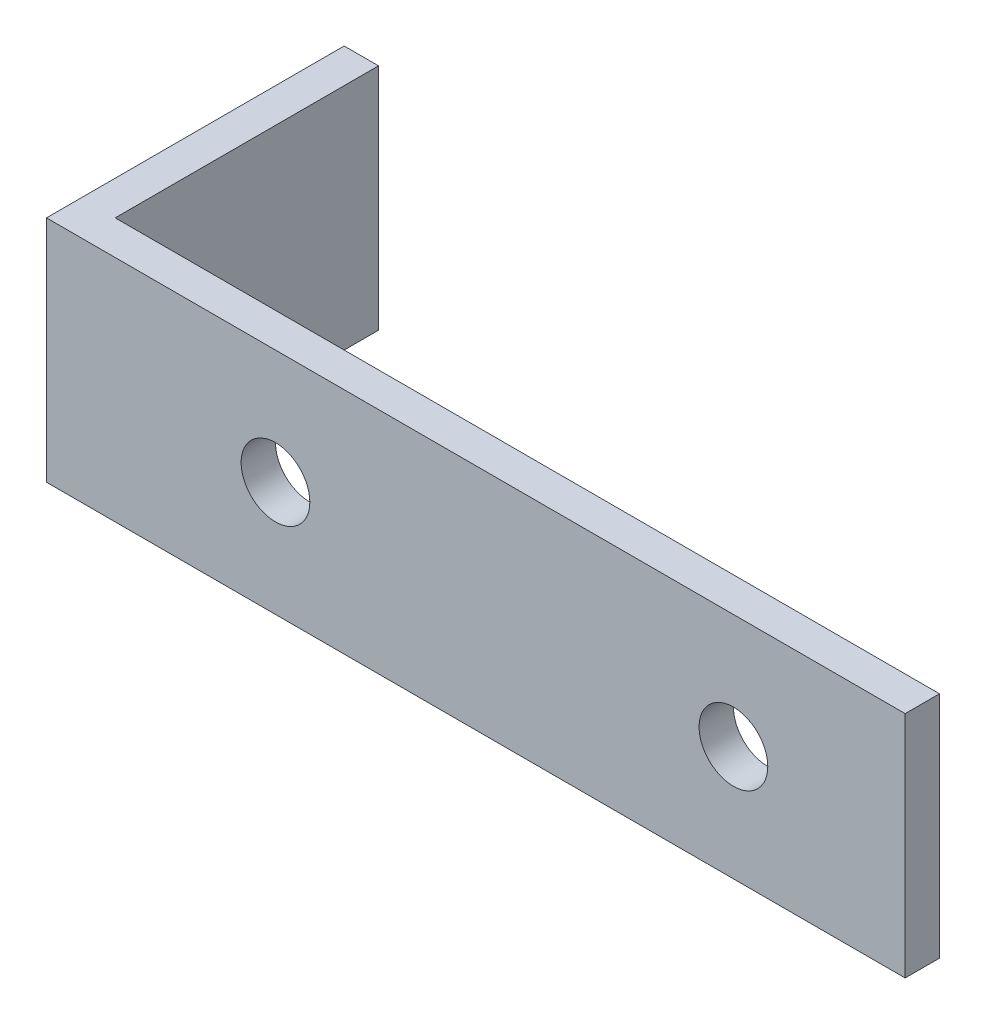
from build123d import *

# Parameters (mm, degrees)
SKETCH1_W           = 75
SKETCH1_H           = 20
SKETCH1_R           = 3
BOSS_EXTRUDE2_DEPTH = 3
SKETCH1_3_W         = 3
SKETCH1_3_H         = 20
BOSS_EXTRUDE3_DEPTH = 23


with BuildPart() as part:
    # Sketch1 → Boss-Extrude2 (new body)
    with BuildSketch(Plane.XY):
        with Locations((37.5, 10)):
            Rectangle(SKETCH1_W, SKETCH1_H)
        with Locations((60, 10)):
            Circle(SKETCH1_R, mode=Mode.SUBTRACT)
        with Locations((20, 10)):
            Circle(SKETCH1_R, mode=Mode.SUBTRACT)
    extrude(amount=BOSS_EXTRUDE2_DEPTH)

    # Sketch1_3 → Boss-Extrude3 (add)
    with BuildSketch(Plane.XY):
        with Locations((1.5, 10)):
            Rectangle(SKETCH1_3_W, SKETCH1_3_H)
    extrude(amount=-BOSS_EXTRUDE3_DEPTH)


solid = part.part
